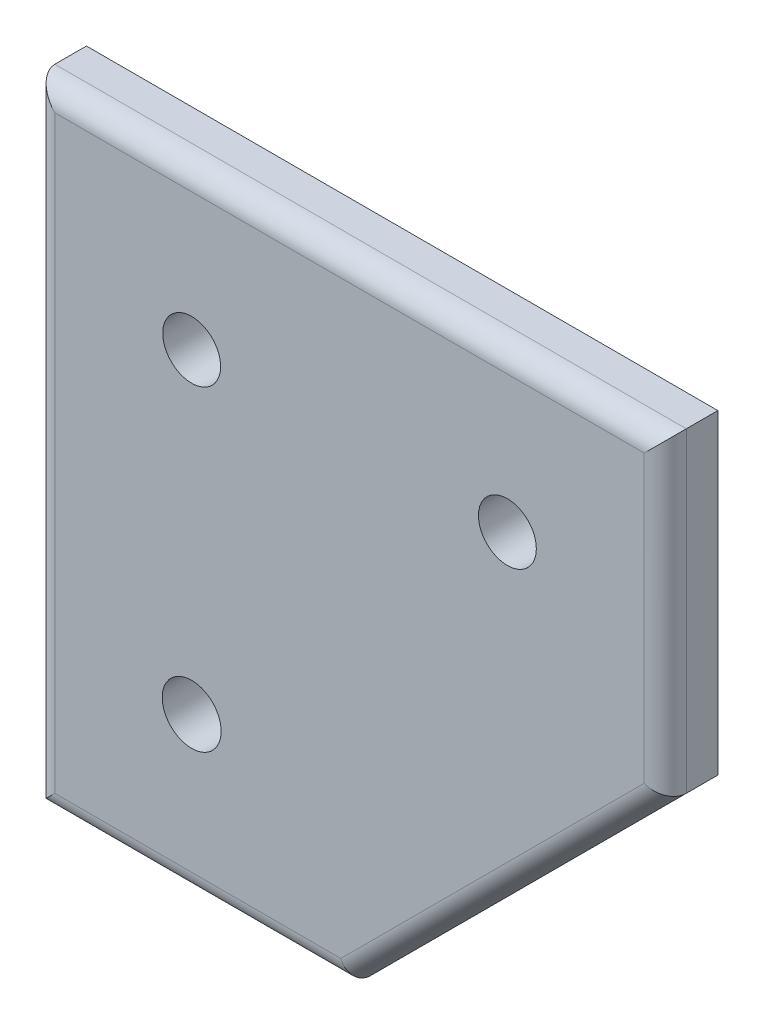
from build123d import *

# Parameters (mm, degrees)
BOSS_EXTRUDE1_DEPTH = 6.35
SKETCH2_R           = 3.4925
SKETCH2_R_2         = 3.556
CUT_EXTRUDE1_DEPTH  = 6.35
FILLET1_R           = 2.54


with BuildPart() as part:
    # Sketch1 → Boss-Extrude1 (new body)
    with BuildSketch(Plane.XY):
        Polygon((38.1, -38.1), (76.2, 0), (76.2, 38.1), (0, 38.1), (0, 0), (0, -38.1), align=None)
    extrude(amount=BOSS_EXTRUDE1_DEPTH)

    # Sketch2 → Cut-Extrude1 (cut)
    with BuildSketch(Plane.XY.offset(6.35)):
        with Locations((19.05, 19.05)):
            Circle(SKETCH2_R)
        with Locations((57.15, 19.05)):
            Circle(SKETCH2_R)
        with Locations((19.05, -19.05)):
            Circle(SKETCH2_R_2)
    extrude(amount=-CUT_EXTRUDE1_DEPTH, mode=Mode.SUBTRACT)

    # Fillet1
    fillet1_edges = [part.edges().sort_by_distance(p)[0] for p in [
        (57.15, -19.05, 6.35),
        (76.2, 19.05, 6.35),
        (38.1, 38.1, 6.35),
        (0, 0, 6.35),
        (19.05, -38.1, 6.35),
    ]]
    fillet(fillet1_edges, radius=FILLET1_R)


solid = part.part
